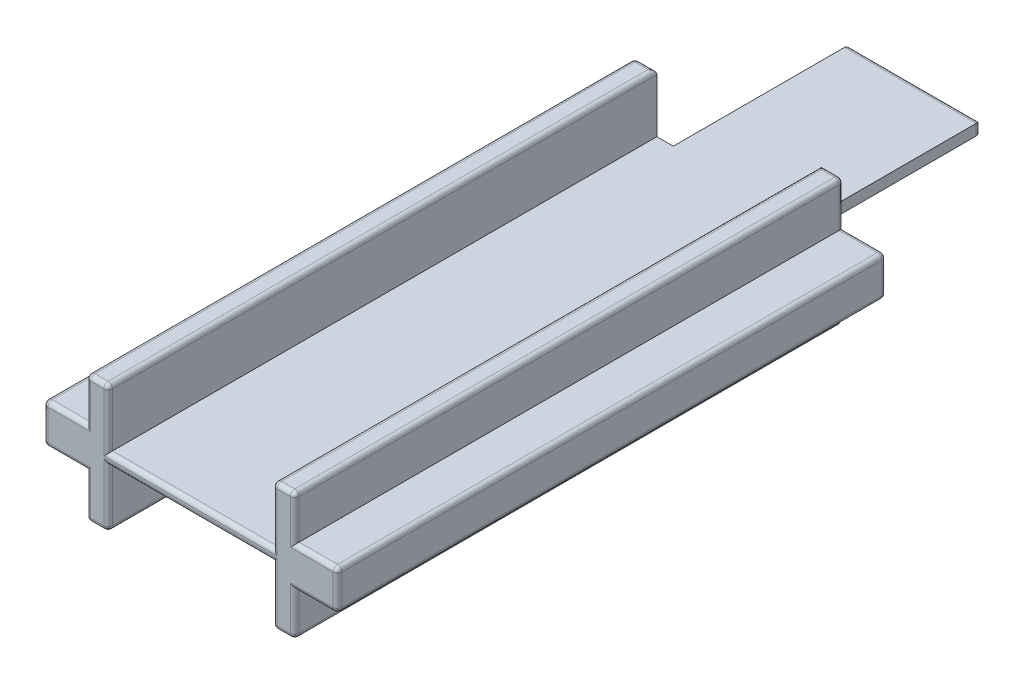
from build123d import *

# Parameters (mm, degrees)
AUFSATZ_LINEAR_AUSTRAGEN1_DEPTH = 25
SKIZZE2_W                       = 6
SKIZZE2_H                       = 1.8
AUFSATZ_LINEAR_AUSTRAGEN2_DEPTH = 8
SKIZZE3_W                       = 7.5
SKIZZE3_H                       = 0.65
SCHNITT_LINEAR_AUSTRAGEN1_DEPTH = 34
VERRUNDUNG1_R                   = 0.2


with BuildPart() as part:
    # Skizze1 → Aufsatz-Linear austragen1 (new body)
    with BuildSketch(Plane.XY):
        Polygon((-4.75, 0.9), (-6.7, 0.9), (-6.7, -0.9), (-4.75, -0.9), (-4.75, -2.9), (-3.75, -2.9), (-3.75, -0.9), (3.75, -0.9), (3.75, -2.9), (4.75, -2.9), (4.75, -0.9), (6.7, -0.9), (6.7, 0.9), (4.75, 0.9), (4.75, 2.9), (3.75, 2.9), (3.75, 0.9), (-3.75, 0.9), (-3.75, 2.9), (-4.75, 2.9), align=None)
    extrude(amount=AUFSATZ_LINEAR_AUSTRAGEN1_DEPTH)

    # Skizze2 → Aufsatz-Linear austragen2 (add)
    with BuildSketch(Plane(origin=(0, 0, 0), x_dir=(-1, 0, 0), z_dir=(0, 0, -1))):
        Rectangle(SKIZZE2_W, SKIZZE2_H)
    extrude(amount=AUFSATZ_LINEAR_AUSTRAGEN2_DEPTH)

    # Skizze3 → Schnitt-Linear austragen1 (cut, through all)
    with BuildSketch(Plane.XY.offset(25)):
        with Locations((0, -0.575)):
            Rectangle(SKIZZE3_W, SKIZZE3_H)
        with Locations((0, 0.575)):
            Rectangle(SKIZZE3_W, SKIZZE3_H)
    extrude(amount=-SCHNITT_LINEAR_AUSTRAGEN1_DEPTH, mode=Mode.SUBTRACT)

    # Verrundung1
    verrundung1_edges = [part.edges().sort_by_distance(p)[0] for p in [
        (0, 0.25, 25),
        (-4.75, -1.9, 25),
        (-4.25, -2.9, 25),
        (-5.725, 0.9, 0),
        (-4.75, 1.9, 0),
        (-4.25, 2.9, 0),
        (-3.75, -1.575, 25),
        (4.25, 2.9, 0),
        (4.75, 1.9, 0),
        (5.725, 0.9, 0),
        (6.7, 0, 0),
        (5.725, -0.9, 0),
        (4.75, -1.9, 0),
        (4.25, -2.9, 0),
        (-4.25, -2.9, 0),
        (-4.75, -1.9, 0),
        (-5.725, -0.9, 0),
        (-6.7, 0, 0),
        (3.75, -1.575, 25),
        (4.25, -2.9, 25),
        (-6.7, 0.9, 12.5),
        (-4.75, 2.9, 12.5),
        (-3.75, 2.9, 12.5),
        (3.75, 2.9, 12.5),
        (4.75, 2.9, 12.5),
        (6.7, 0.9, 12.5),
        (6.7, -0.9, 12.5),
        (4.75, -2.9, 12.5),
        (3.75, -2.9, 12.5),
        (-3.75, -2.9, 12.5),
        (-4.75, -2.9, 12.5),
        (-6.7, -0.9, 12.5),
        (4.75, -1.9, 25),
        (5.725, -0.9, 25),
        (6.7, 0, 25),
        (5.725, 0.9, 25),
        (-6.7, 0, 25),
        (4.75, 1.9, 25),
        (4.25, 2.9, 25),
        (3.75, 1.575, 25),
        (-3.75, 1.575, 25),
        (3, 0, -8),
        (-3, 0, -8),
        (-4.25, 2.9, 25),
        (0, 0.25, -8),
        (0, -0.25, -8),
        (-4.75, 1.9, 25),
        (-5.725, 0.9, 25),
        (0, -0.25, 25),
        (-5.725, -0.9, 25),
    ]]
    fillet(verrundung1_edges, radius=VERRUNDUNG1_R)


solid = part.part
